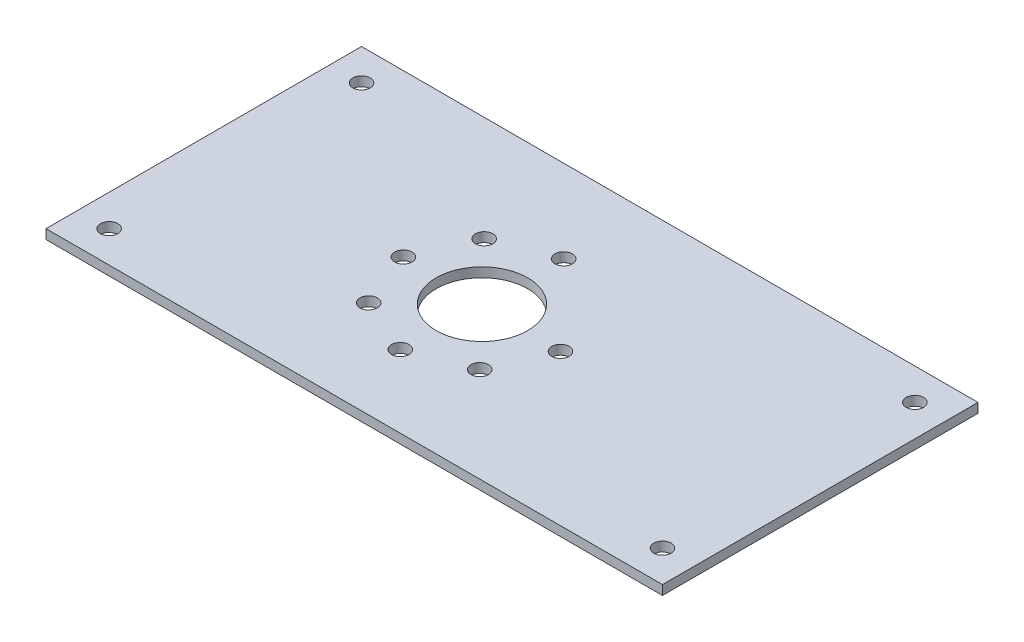
from build123d import *

# Parameters (mm, degrees)
SKETCH1_W           = 195.38
SKETCH1_H           = 100
BOSS_EXTRUDE1_DEPTH = 3
SKETCH2_R           = 2.75
CUT_EXTRUDE1_DEPTH  = 4
SKETCH3_R           = 2.75
SKETCH3_R_2         = 14.5
CUT_EXTRUDE2_DEPTH  = 4


with BuildPart() as part:
    # Sketch1 → Boss-Extrude1 (new body)
    with BuildSketch(Plane(origin=(0, 0, 0), x_dir=(1, 0, 0), z_dir=(0, 1, 0))):
        with Locations((97.69, -50)):
            Rectangle(SKETCH1_W, SKETCH1_H)
    extrude(amount=BOSS_EXTRUDE1_DEPTH)

    # Sketch2 → Cut-Extrude1 (cut, through all)
    with BuildSketch(Plane(origin=(0, 3, 0), x_dir=(1, 0, 0), z_dir=(0, 1, 0))):
        with Locations((185.38, -10)):
            Circle(SKETCH2_R)
        with Locations((185.38, -90)):
            Circle(SKETCH2_R)
        with Locations((10, -90)):
            Circle(SKETCH2_R)
        with Locations((10, -10)):
            Circle(SKETCH2_R)
    extrude(amount=-CUT_EXTRUDE1_DEPTH, mode=Mode.SUBTRACT)

    # Sketch3 → Cut-Extrude2 (cut, through all)
    with BuildSketch(Plane(origin=(0, 3, 0), x_dir=(1, 0, 0), z_dir=(0, 1, 0))):
        with Locations((90.316911264, -26.256219724)):
            Circle(SKETCH3_R)
        with Locations((72.212744361, -33.338953579)):
            Circle(SKETCH3_R)
        with Locations((64.419414315, -51.148781901)):
            Circle(SKETCH3_R)
        with Locations((115.209473441, -52.153716673)):
            Circle(SKETCH3_R)
        with Locations((107.416143395, -69.963544996)):
            Circle(SKETCH3_R)
        with Locations((89.311976492, -77.046278851)):
            Circle(SKETCH3_R)
        with Locations((71.50214817, -69.252948804)):
            Circle(SKETCH3_R)
        with Locations((89.814443878, -51.651249287)):
            Circle(SKETCH3_R_2)
    extrude(amount=-CUT_EXTRUDE2_DEPTH, mode=Mode.SUBTRACT)


solid = part.part
